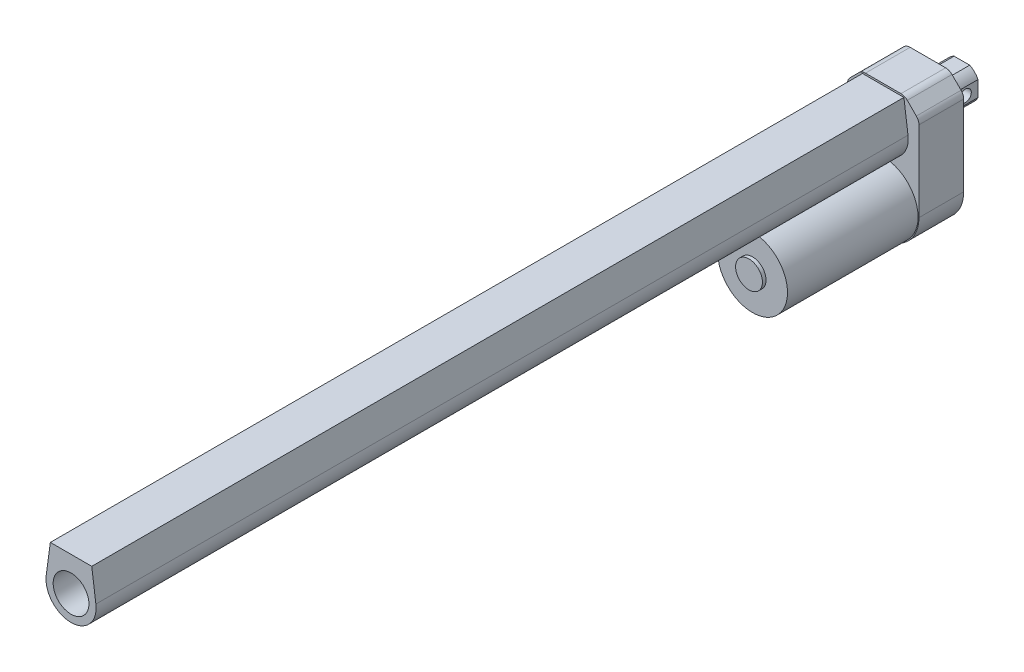
from build123d import *

# Parameters (mm, degrees)
EXTRUDE_1_DEPTH     = 25
SKETCH_2_R          = 19.5
EXTRUDE_2_DEPTH     = 73
SKETCH_3_R          = 7.5
EXTRUDE_3_DEPTH     = 2
EXTRUDE_4_DEPTH     = 454
SKETCH_5_R          = 10
CUT_EXTRUDE_1_DEPTH = 410
EXTRUDE_5_DEPTH     = 19
SKETCH_7_R          = 3.25
CUT_EXTRUDE_2_DEPTH = 19


with BuildPart() as part:
    # 草图1 → 凸台-拉伸1 (new body)
    with BuildSketch(Plane.XY):
        with BuildLine():
            Line((-20, 0), (-20, 44.928932188))
            ThreePointArc((-20, 44.928932188), (-19.619397663, 46.84234935), (-18.535533906, 48.464466094))
            Line((-18.535533906, 48.464466094), (-13.464466094, 53.535533906))
            ThreePointArc((-13.464466094, 53.535533906), (-11.84234935, 54.619397663), (-9.928932188, 55))
            Line((-9.928932188, 55), (9.928932188, 55))
            ThreePointArc((9.928932188, 55), (11.84234935, 54.619397663), (13.464466094, 53.535533906))
            Line((13.464466094, 53.535533906), (18.535533906, 48.464466094))
            ThreePointArc((18.535533906, 48.464466094), (19.619397663, 46.84234935), (20, 44.928932188))
            Line((20, 44.928932188), (20, 0))
            ThreePointArc((20, 0), (0, -20), (-20, 0))
        make_face()
    extrude(amount=EXTRUDE_1_DEPTH)

    # 草图2 → 凸台-拉伸2 (add)
    with BuildSketch(Plane.XY.offset(25)):
        Circle(SKETCH_2_R)
    extrude(amount=EXTRUDE_2_DEPTH)

    # 草图3 → 凸台-拉伸3 (add)
    with BuildSketch(Plane.XY.offset(98)):
        Circle(SKETCH_3_R)
    extrude(amount=EXTRUDE_3_DEPTH)

    # 草图4 → 凸台-拉伸4 (add)
    with BuildSketch(Plane.XY.offset(25)):
        with BuildLine():
            Line((-11.576521962, 54), (-13.87569737, 36.861457087))
            ThreePointArc((-13.87569737, 36.861457087), (0, 21), (13.87569737, 36.861457087))
            Line((13.87569737, 36.861457087), (11.576521962, 54))
            Line((11.576521962, 54), (-11.576521962, 54))
        make_face()
    extrude(amount=EXTRUDE_4_DEPTH)

    # 草图5 → 切除-拉伸1 (cut)
    with BuildSketch(Plane.XY.offset(479)):
        with Locations((0, 35)):
            Circle(SKETCH_5_R)
    extrude(amount=-CUT_EXTRUDE_1_DEPTH, mode=Mode.SUBTRACT)

    # 草图6 → 凸台-拉伸5 (add)
    with BuildSketch(Plane(origin=(0, 0, 0), x_dir=(-1, 0, 0), z_dir=(0, 0, -1))):
        with BuildLine():
            Line((-4.358898944, 44), (4.358898944, 44))
            ThreePointArc((4.358898944, 44), (7.071067812, 42.071067812), (9, 39.358898944))
            Line((9, 39.358898944), (9, 30.641101056))
            ThreePointArc((9, 30.641101056), (7.071067812, 27.928932188), (4.358898944, 26))
            Line((4.358898944, 26), (-4.358898944, 26))
            ThreePointArc((-4.358898944, 26), (-7.071067812, 27.928932188), (-9, 30.641101056))
            Line((-9, 30.641101056), (-9, 39.358898944))
            ThreePointArc((-9, 39.358898944), (-7.071067812, 42.071067812), (-4.358898944, 44))
        make_face()
    extrude(amount=EXTRUDE_5_DEPTH)

    # 草图7 → 切除-拉伸2 (cut)
    with BuildSketch(Plane(origin=(9, 0, 0), x_dir=(0, 0, -1), z_dir=(1, 0, 0))):
        with Locations((12, 35)):
            Circle(SKETCH_7_R)
    extrude(amount=-CUT_EXTRUDE_2_DEPTH, mode=Mode.SUBTRACT)


solid = part.part
